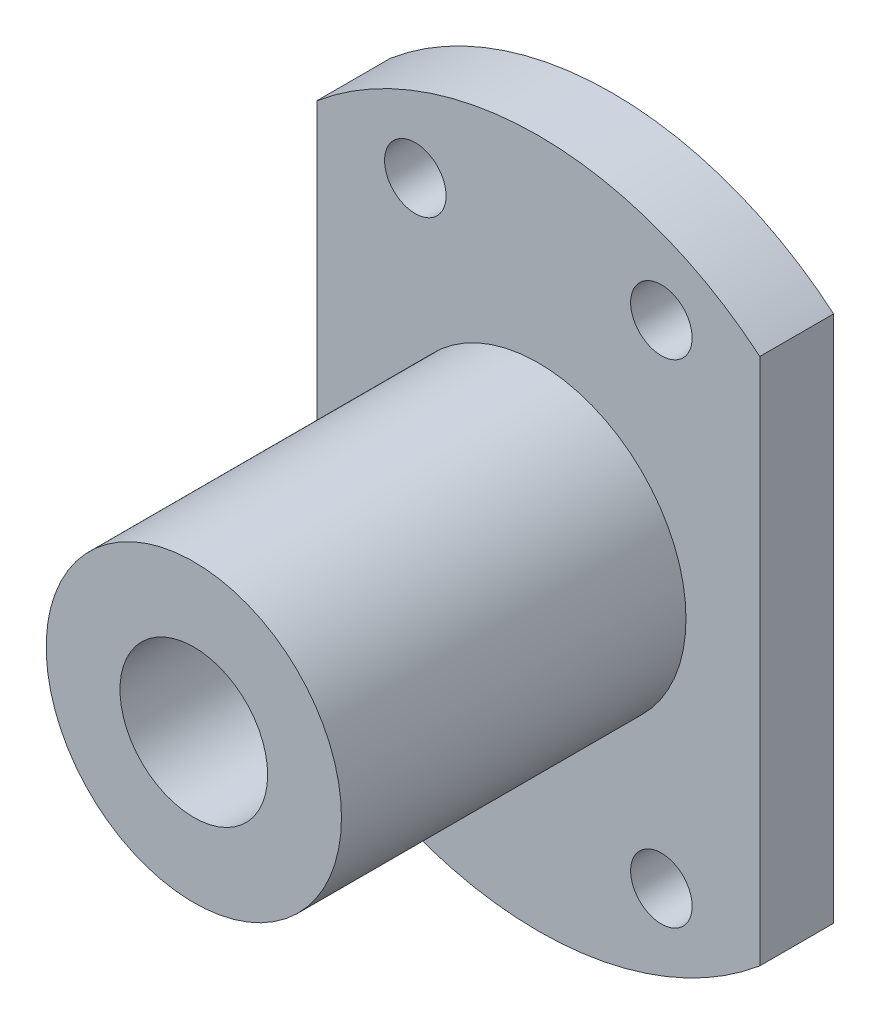
from build123d import *

# Parameters (mm, degrees)
SKETCH1_R               = 3
SKETCH1_R_2             = 1.25
BOSS_EXTRUDE1_DEPTH     = 3
SKETCH2_R               = 6
SKETCH2_R_2             = 3
LINEARBALLSUPPORT_DEPTH = 14


with BuildPart() as part:
    # Sketch1 → Boss-Extrude1 (new body)
    with BuildSketch(Plane.XY):
        with BuildLine():
            Line((-9, 10.723805295), (-9, -10.723805295))
            ThreePointArc((-9, -10.723805295), (0, -14), (9, -10.723805295))
            Line((9, -10.723805295), (9, 10.723805295))
            ThreePointArc((9, 10.723805295), (0, 14), (-9, 10.723805295))
        make_face()
        Circle(SKETCH1_R, mode=Mode.SUBTRACT)
        with Locations((-5, 10)):
            Circle(SKETCH1_R_2, mode=Mode.SUBTRACT)
        with Locations((5, 10)):
            Circle(SKETCH1_R_2, mode=Mode.SUBTRACT)
        with Locations((-5, -10)):
            Circle(SKETCH1_R_2, mode=Mode.SUBTRACT)
        with Locations((5, -10)):
            Circle(SKETCH1_R_2, mode=Mode.SUBTRACT)
    extrude(amount=BOSS_EXTRUDE1_DEPTH)

    # Sketch2 → LinearBallSupport (add)
    with BuildSketch(Plane.XY.offset(3)):
        Circle(SKETCH2_R)
        Circle(SKETCH2_R_2, mode=Mode.SUBTRACT)
    extrude(amount=LINEARBALLSUPPORT_DEPTH)


solid = part.part
